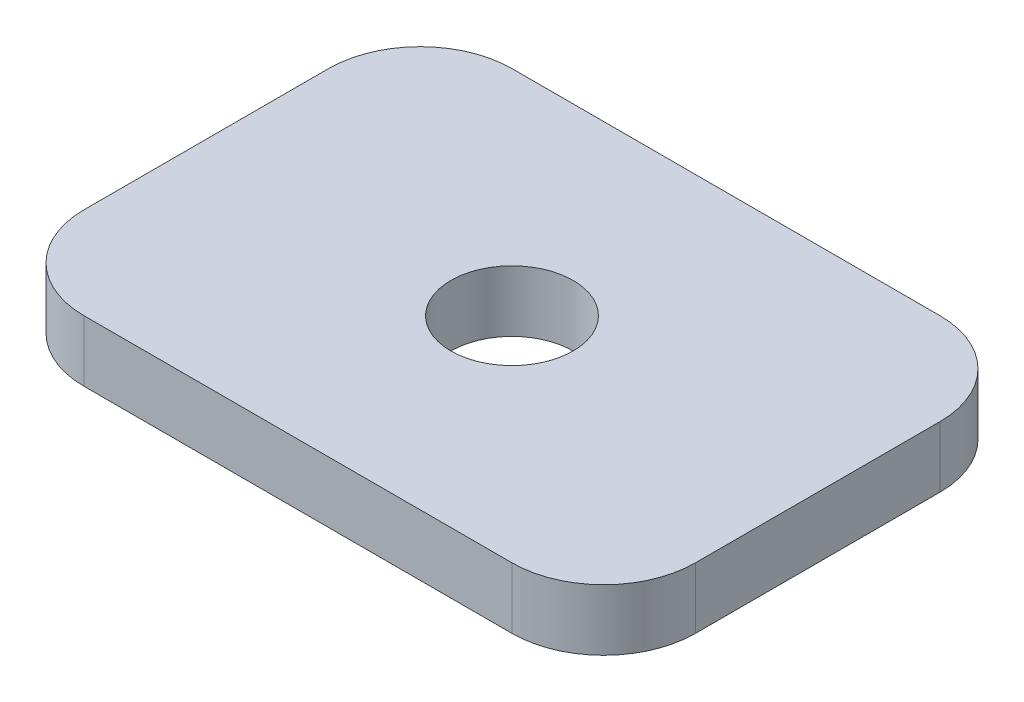
from build123d import *

# Parameters (mm, degrees)
SKETCH1_W                 = 100
SKETCH1_H                 = 70
BOSS_EXTRUDE1_DEPTH       = 10
SKETCH2_R                 = 10
CUT_EXTRUDE1_DEPTH        = 11
F_3_0MM_DOWEL_HOLE1_D     = 3
F_3_0MM_DOWEL_HOLE1_DEPTH = 5
F_3_0MM_DOWEL_HOLE1_TIP   = 0.901290929
FILLET2_R                 = 15


with BuildPart() as part:
    # Sketch1 → Boss-Extrude1 (new body)
    with BuildSketch(Plane(origin=(0, 0, 0), x_dir=(1, 0, 0), z_dir=(0, 1, 0))):
        Rectangle(SKETCH1_W, SKETCH1_H)
    extrude(amount=BOSS_EXTRUDE1_DEPTH)

    # Sketch2 → Cut-Extrude1 (cut, through all)
    with BuildSketch(Plane(origin=(0, 10, 0), x_dir=(1, 0, 0), z_dir=(0, 1, 0))):
        Circle(SKETCH2_R)
    extrude(amount=-CUT_EXTRUDE1_DEPTH, mode=Mode.SUBTRACT)

    # Ø3.0mm Dowel Hole1
    with Locations(Plane(origin=(0, 0, 0), x_dir=(-1, 0, 0), z_dir=(0, -1, 0))):
        with Locations((40, 0), (-40, 0)):
            Hole(F_3_0MM_DOWEL_HOLE1_D / 2, depth=F_3_0MM_DOWEL_HOLE1_DEPTH)
            with Locations((0, 0, -(F_3_0MM_DOWEL_HOLE1_DEPTH + F_3_0MM_DOWEL_HOLE1_TIP / 2))):  # 118° drill point
                Cone(0, F_3_0MM_DOWEL_HOLE1_D / 2, F_3_0MM_DOWEL_HOLE1_TIP, mode=Mode.SUBTRACT)

    # Fillet2
    fillet2_edges = [part.edges().sort_by_distance(p)[0] for p in [
        (-50, 5, -35),
        (50, 5, -35),
        (50, 5, 35),
        (-50, 5, 35),
    ]]
    fillet(fillet2_edges, radius=FILLET2_R)


solid = part.part
